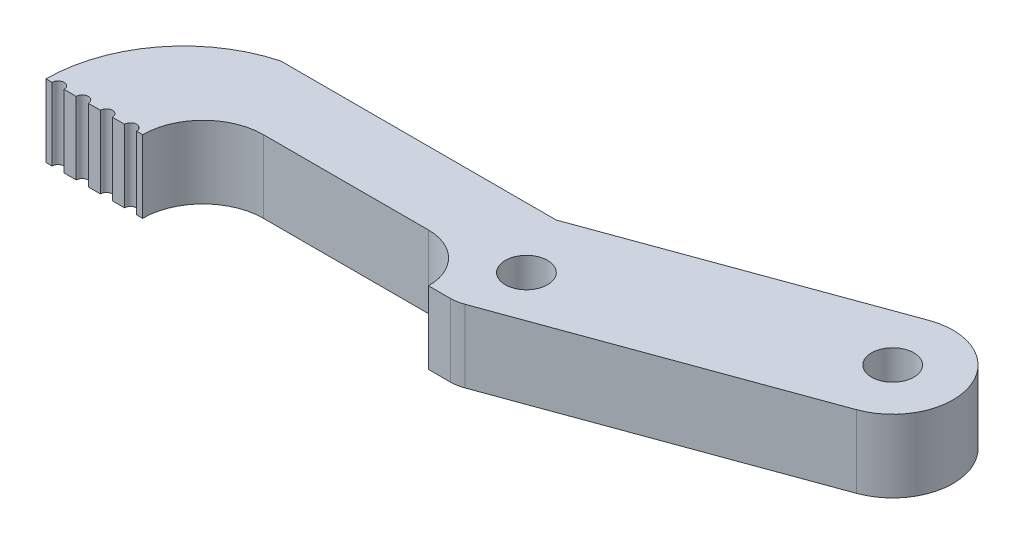
from build123d import *

# Parameters (mm, degrees)
SKETCH_1_R          = 1.75
EXTRUDE_1_DEPTH     = 6
FILLET_1_R          = 3
SKETCH_2_R          = 0.5
CUT_EXTRUDE_1_DEPTH = 7


with BuildPart() as part:
    # Эскиз1 → Бобышка-Вытянуть1 (new body)
    with BuildSketch(Plane(origin=(0, 0, 0), x_dir=(1, 0, 0), z_dir=(0, 1, 0))):
        with BuildLine():
            Line((-3.991673782, 0), (4.008326218, 0))
            ThreePointArc((4.008326218, 0), (5.472792312, 3.535533906), (9.008326218, 5))
            Line((9.008326218, 5), (22.681786604, 5))
            ThreePointArc((22.681786604, 5), (25.510213728, 3.828427125), (26.681786604, 1))
            Line((26.681786604, 1), (29.008326218, 1))
            Line((29.008326218, 1), (53.280650212, 9.83440345))
            ThreePointArc((53.280650212, 9.83440345), (56.269012599, 16.242967271), (49.860448779, 19.231329658))
            Line((49.860448779, 19.231329658), (27.245056411, 11))
            Line((27.245056411, 11), (4.445056411, 11))
            ThreePointArc((4.445056411, 11), (-1.63962848, 6.931421506), (-3.991673782, 0))
        make_face()
        with Locations((51.570549496, 14.532866554)):
            Circle(SKETCH_1_R, mode=Mode.SUBTRACT)
        with Locations((29.781786604, 6)):
            Circle(SKETCH_1_R, mode=Mode.SUBTRACT)
    extrude(amount=EXTRUDE_1_DEPTH)

    # Скругление1
    fillet_1_edges = [part.edges().sort_by_distance(p)[0] for p in [
        (29.008326218, 3, -1),
    ]]
    fillet(fillet_1_edges, radius=FILLET_1_R)

    # Эскиз2 → Вырез-Вытянуть1 (cut, through all)
    with BuildSketch(Plane(origin=(0, 6, 0), x_dir=(1, 0, 0), z_dir=(0, 1, 0))):
        with Locations((1.008326218, 0)):
            Circle(SKETCH_2_R)
        with Locations((3.008326218, 0)):
            Circle(SKETCH_2_R)
        with Locations((-0.991673782, 0)):
            Circle(SKETCH_2_R)
        with Locations((-2.991673782, 0)):
            Circle(SKETCH_2_R)
    extrude(amount=-CUT_EXTRUDE_1_DEPTH, mode=Mode.SUBTRACT)


solid = part.part
